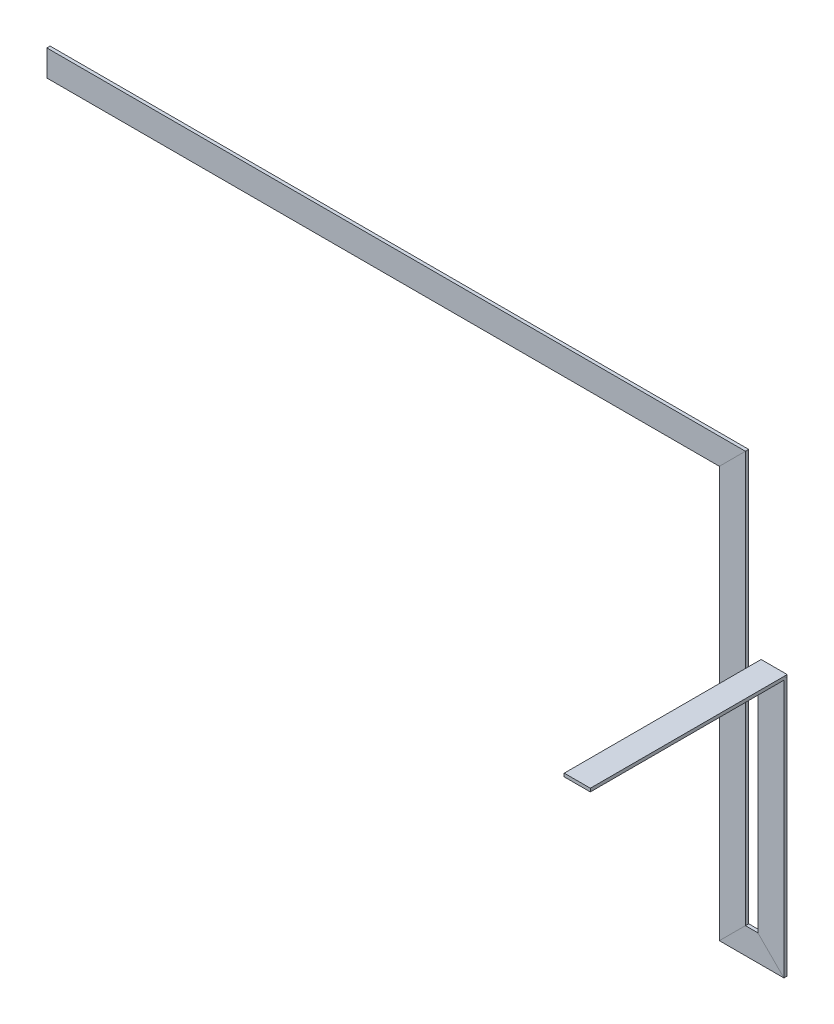
from build123d import *

# Parameters (mm, degrees)
CROQUIS3_W              = 50.8
CROQUIS3_H              = 6.35
CROQUIS4_W              = 50.8
CROQUIS4_H              = 6.35
SALIENTE_EXTRUIR1_DEPTH = 377
CROQUIS5_W              = 50.8
CROQUIS5_H              = 70.739551551
CORTAR_EXTRUIR1_DEPTH   = 8


with BuildPart() as part:
    # Barrer1: sweep along a curve in space
    with BuildLine() as barrer1_path:
        Line((62.290853195, 217.5, 0), (62.290853195, 217.5, 73.914551551))
        Line((62.290853195, 217.5, 73.914551551), (62.290853195, -262.5, 73.914551551))
        Line((62.290853195, -262.5, 73.914551551), (-12.709146805, -262.5, 73.914551551))
        Line((-12.709146805, -262.5, 73.914551551), (-12.709146805, 537.5, 73.914551551))
        Line((-12.709146805, 537.5, 73.914551551), (-1347.700875805, 537.5, 73.914551551))
    # Croquis3 → Barrer1 (sweep)
    with BuildSketch(Plane.XY):
        with Locations((62.290853195, 217.5)):
            Rectangle(CROQUIS3_W, CROQUIS3_H)
    sweep(path=barrer1_path.line, transition=Transition.RIGHT)

    # Croquis4 → Saliente-Extruir1 (add)
    with BuildSketch(Plane.XY.offset(77.089551551)):
        with Locations((62.290853195, 217.5)):
            Rectangle(CROQUIS4_W, CROQUIS4_H)
    extrude(amount=SALIENTE_EXTRUIR1_DEPTH)

    # Croquis5 → Cortar-Extruir1 (cut)
    with BuildSketch(Plane(origin=(0, 220.675, 0), x_dir=(1, 0, 0), z_dir=(0, 1, 0))):
        with Locations((62.290853195, -35.369775776)):
            Rectangle(CROQUIS5_W, CROQUIS5_H)
    extrude(amount=-CORTAR_EXTRUIR1_DEPTH, mode=Mode.SUBTRACT)


solid = part.part
